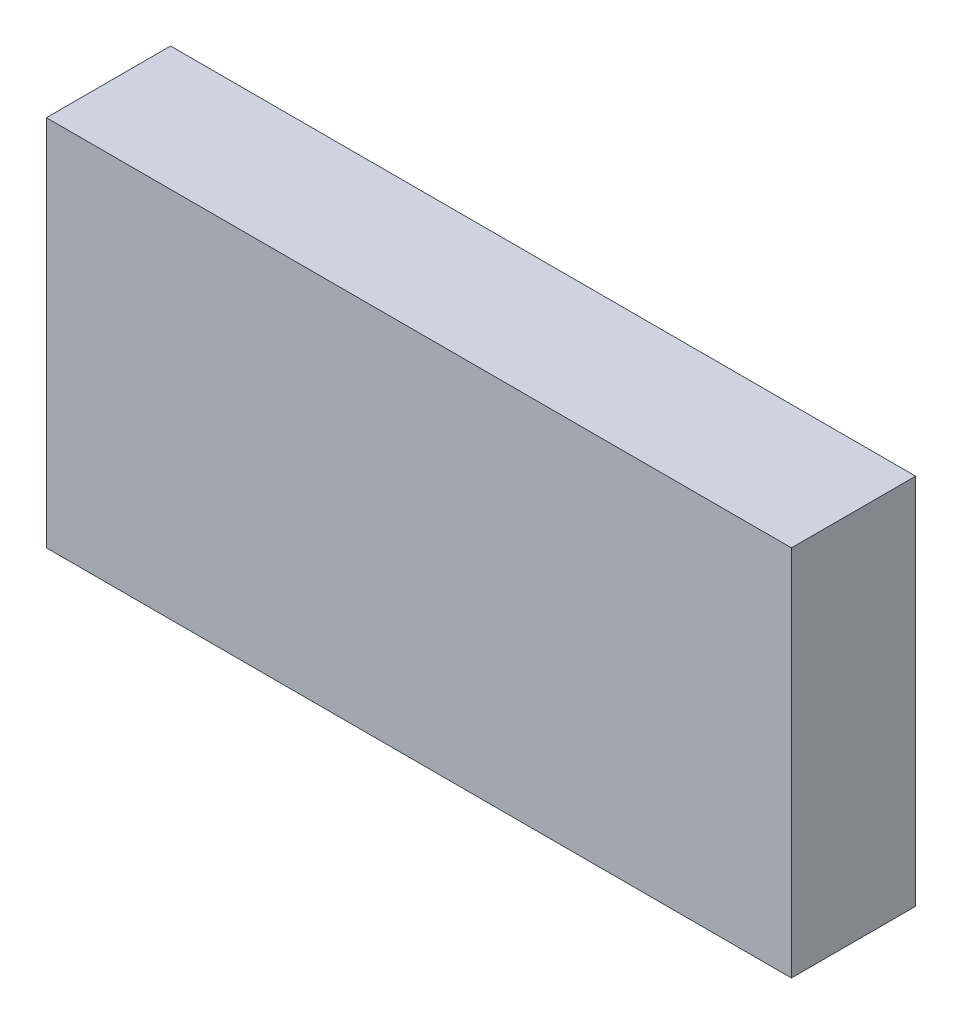
from build123d import *

# Parameters (mm, degrees)
SKETCH1_W           = 6000
SKETCH1_H           = 3000
BOSS_EXTRUDE1_DEPTH = 1000


with BuildPart() as part:
    # Sketch1 → Boss-Extrude1 (new body)
    with BuildSketch(Plane.XY):
        Rectangle(SKETCH1_W, SKETCH1_H)
    extrude(amount=BOSS_EXTRUDE1_DEPTH)


solid = part.part
